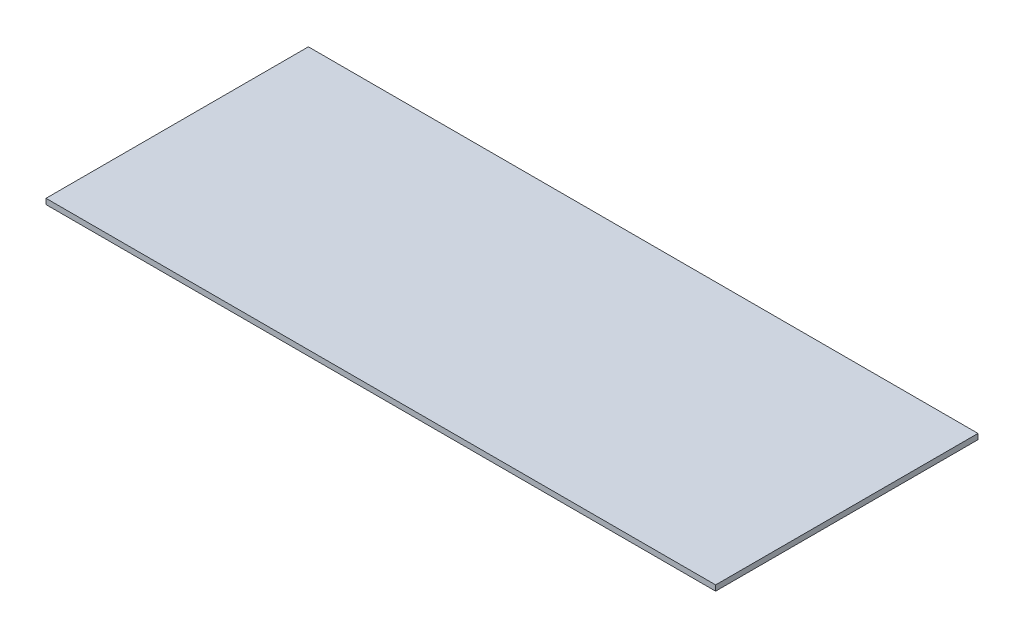
from build123d import *

# Parameters (mm, degrees)
SKETCH2_W           = 245
SKETCH2_H           = 96
BOSS_EXTRUDE1_DEPTH = 2


with BuildPart() as part:
    # Sketch2 → Boss-Extrude1 (new body)
    with BuildSketch(Plane(origin=(0, 0, 0), x_dir=(1, 0, 0), z_dir=(0, 1, 0))):
        Rectangle(SKETCH2_W, SKETCH2_H)
    extrude(amount=BOSS_EXTRUDE1_DEPTH)


solid = part.part
